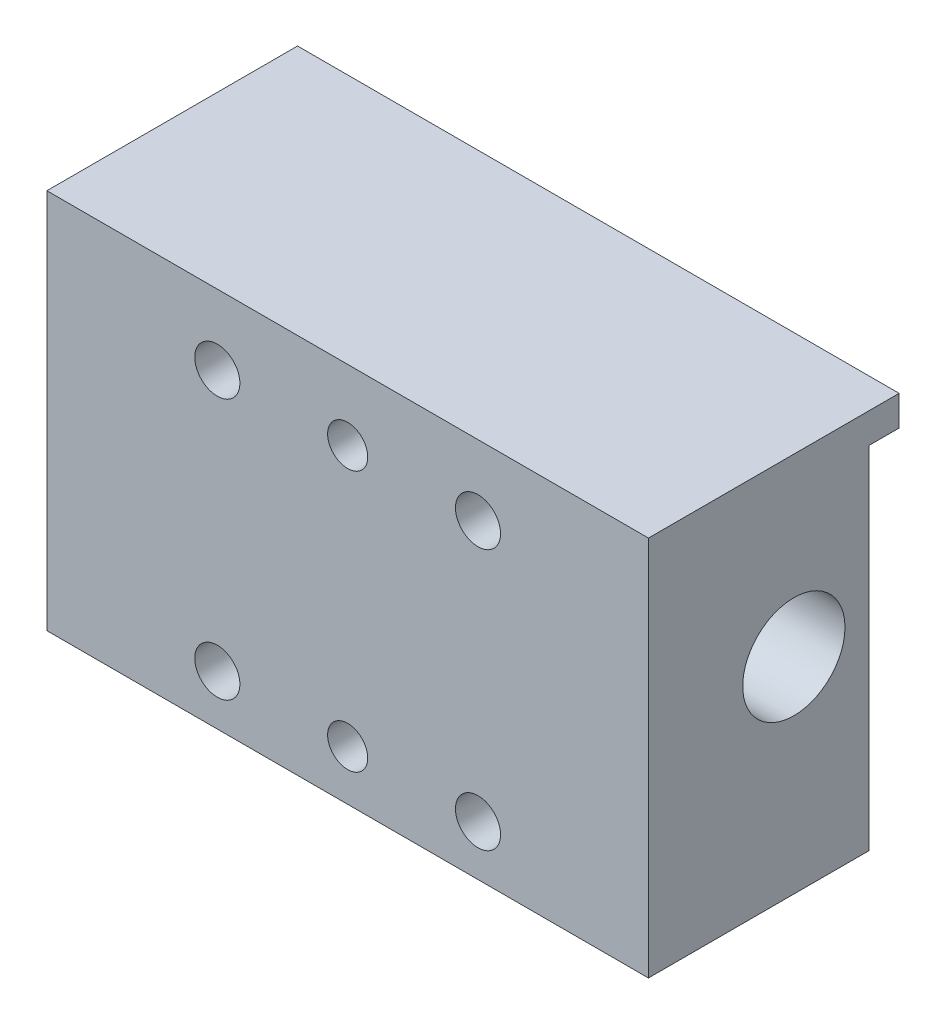
from build123d import *

# Parameters (mm, degrees)
CROQUIS1_W                                     = 60
CROQUIS1_H                                     = 38
SALIENTE_EXTRUIR1_DEPTH                        = 22
CROQUIS2_R                                     = 5.1
CORTAR_EXTRUIR1_DEPTH                          = 61
CROQUIS6_W                                     = 60
CROQUIS6_H                                     = 3
SALIENTE_EXTRUIR2_DEPTH                        = 3
PERFORADOR_PARA_ROSCAR_PARA_MACHO_DE_ROS_D     = 2.5
PERFORADOR_PARA_ROSCAR_PARA_MACHO_DE_ROS_DEPTH = 14
PERFORADOR_PARA_ROSCAR_PARA_MACHO_DE_ROS_TIP   = 0.751075774
TALADRO_DE_MARGEN_PARA_M41_D                   = 4.5
TALADROS_DE_ESPIGA_DE_4_0MM2_D                 = 4
TALADROS_DE_ESPIGA_DE_4_0MM2_DEPTH             = 14
TALADROS_DE_ESPIGA_DE_4_0MM2_TIP               = 1.201721238


with BuildPart() as part:
    # Croquis1 → Saliente-Extruir1 (new body)
    with BuildSketch(Plane.XY):
        with Locations((30, 19)):
            Rectangle(CROQUIS1_W, CROQUIS1_H)
    extrude(amount=SALIENTE_EXTRUIR1_DEPTH)

    # Croquis2 → Cortar-Extruir1 (cut, through all)
    with BuildSketch(Plane(origin=(60, 0, 0), x_dir=(0, 0, -1), z_dir=(1, 0, 0))):
        with Locations((-7.5, 20.5)):
            Circle(CROQUIS2_R)
    extrude(amount=-CORTAR_EXTRUIR1_DEPTH, mode=Mode.SUBTRACT)

    # Croquis6 → Saliente-Extruir2 (add)
    with BuildSketch(Plane(origin=(0, 0, 0), x_dir=(-1, 0, 0), z_dir=(0, 0, -1))):
        with Locations((-30, 36.5)):
            Rectangle(CROQUIS6_W, CROQUIS6_H)
    extrude(amount=SALIENTE_EXTRUIR2_DEPTH)

    # Perforador para roscar para macho de roscar para M33
    with Locations(Plane.ZY):
        with Locations((15.5, 20.5), (7.5, 12.5), (7.5, 28.5)):
            Hole(PERFORADOR_PARA_ROSCAR_PARA_MACHO_DE_ROS_D / 2, depth=PERFORADOR_PARA_ROSCAR_PARA_MACHO_DE_ROS_DEPTH)
            with Locations((0, 0, -(PERFORADOR_PARA_ROSCAR_PARA_MACHO_DE_ROS_DEPTH + PERFORADOR_PARA_ROSCAR_PARA_MACHO_DE_ROS_TIP / 2))):  # 118° drill point
                Cone(0, PERFORADOR_PARA_ROSCAR_PARA_MACHO_DE_ROS_D / 2, PERFORADOR_PARA_ROSCAR_PARA_MACHO_DE_ROS_TIP, mode=Mode.SUBTRACT)

    # Taladro de margen para M41 (through all)
    with Locations(Plane.XY.offset(22)):
        with Locations((17, 5), (43, 31), (43, 5), (17, 31)):
            Hole(TALADRO_DE_MARGEN_PARA_M41_D / 2)

    # Taladros de espiga de Ø4.0mm2
    with Locations(Plane.XY.offset(22)):
        with Locations((30, 31), (30, 5)):
            Hole(TALADROS_DE_ESPIGA_DE_4_0MM2_D / 2, depth=TALADROS_DE_ESPIGA_DE_4_0MM2_DEPTH)
            with Locations((0, 0, -(TALADROS_DE_ESPIGA_DE_4_0MM2_DEPTH + TALADROS_DE_ESPIGA_DE_4_0MM2_TIP / 2))):  # 118° drill point
                Cone(0, TALADROS_DE_ESPIGA_DE_4_0MM2_D / 2, TALADROS_DE_ESPIGA_DE_4_0MM2_TIP, mode=Mode.SUBTRACT)


solid = part.part
